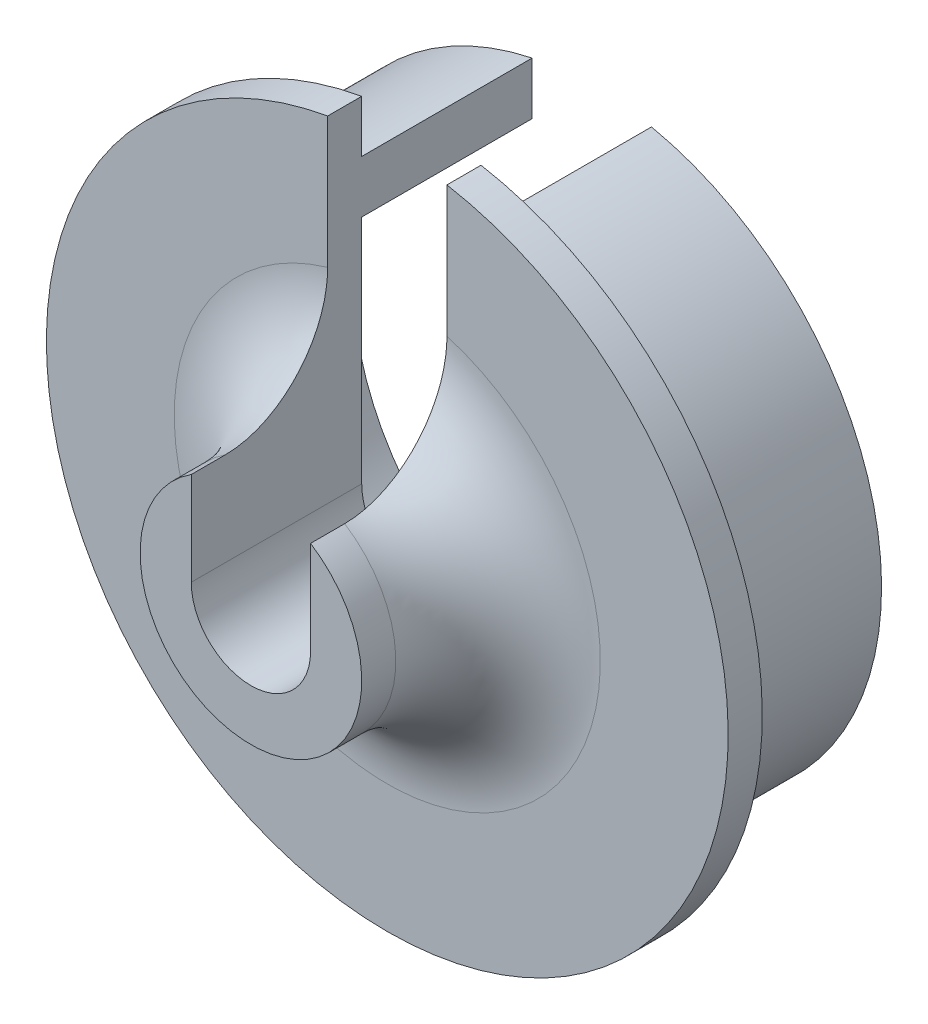
from build123d import *

# Parameters (mm, degrees)
CUT_EXTRUDE1_DEPTH      = 6
CUT_EXTRUDE1_DEPTH_BACK = 6


with BuildPart() as part:
    # Sketch1 → Revolve1 (revolve)
    with BuildSketch(Plane(origin=(0, 0, 0), x_dir=(0, 0, -1), z_dir=(1, 0, 0))):
        with BuildLine():
            Line((0, 1.75), (0, 3.25))
            Line((0, 3.25), (1, 3.25))
            ThreePointArc((1, 3.25), (3.121320344, 4.128679656), (4, 6.25))
            Line((4, 6.25), (4, 10))
            Line((4, 10), (5, 10))
            Line((5, 10), (5, 8.5))
            Line((5, 8.5), (10, 8.5))
            Line((10, 8.5), (10, 7))
            Line((10, 7), (5, 7))
            Line((5, 7), (5, 1.75))
            Line((5, 1.75), (0, 1.75))
        make_face()
    revolve(axis=Axis((0, 0, 0), (0, 0, -1)))

    # Sketch2 → Cut-Extrude1 (cut, two sides)
    with BuildSketch(Plane(origin=(0, 0, -5), x_dir=(-1, 0, 0), z_dir=(0, 0, -1))) as cut_extrude1_sk:
        with BuildLine():
            Line((-1.75, 9.845684334), (-1.75, 6.777720856))
            ThreePointArc((-1.75, 6.777720856), (0, 7), (1.75, 6.777720856))
            Line((1.75, 6.777720856), (1.75, 9.845684334))
            ThreePointArc((1.75, 9.845684334), (0, 10), (-1.75, 9.845684334))
        make_face()
        with BuildLine():
            Line((-1.75, 6.777720856), (-1.75, 0))
            ThreePointArc((-1.75, 0), (0, 1.75), (1.75, 0))
            Line((1.75, 0), (1.75, 6.777720856))
            ThreePointArc((1.75, 6.777720856), (0, 7), (-1.75, 6.777720856))
        make_face()
    extrude(amount=CUT_EXTRUDE1_DEPTH, mode=Mode.SUBTRACT)
    extrude(cut_extrude1_sk.sketch, amount=-CUT_EXTRUDE1_DEPTH_BACK, mode=Mode.SUBTRACT)


solid = part.part
